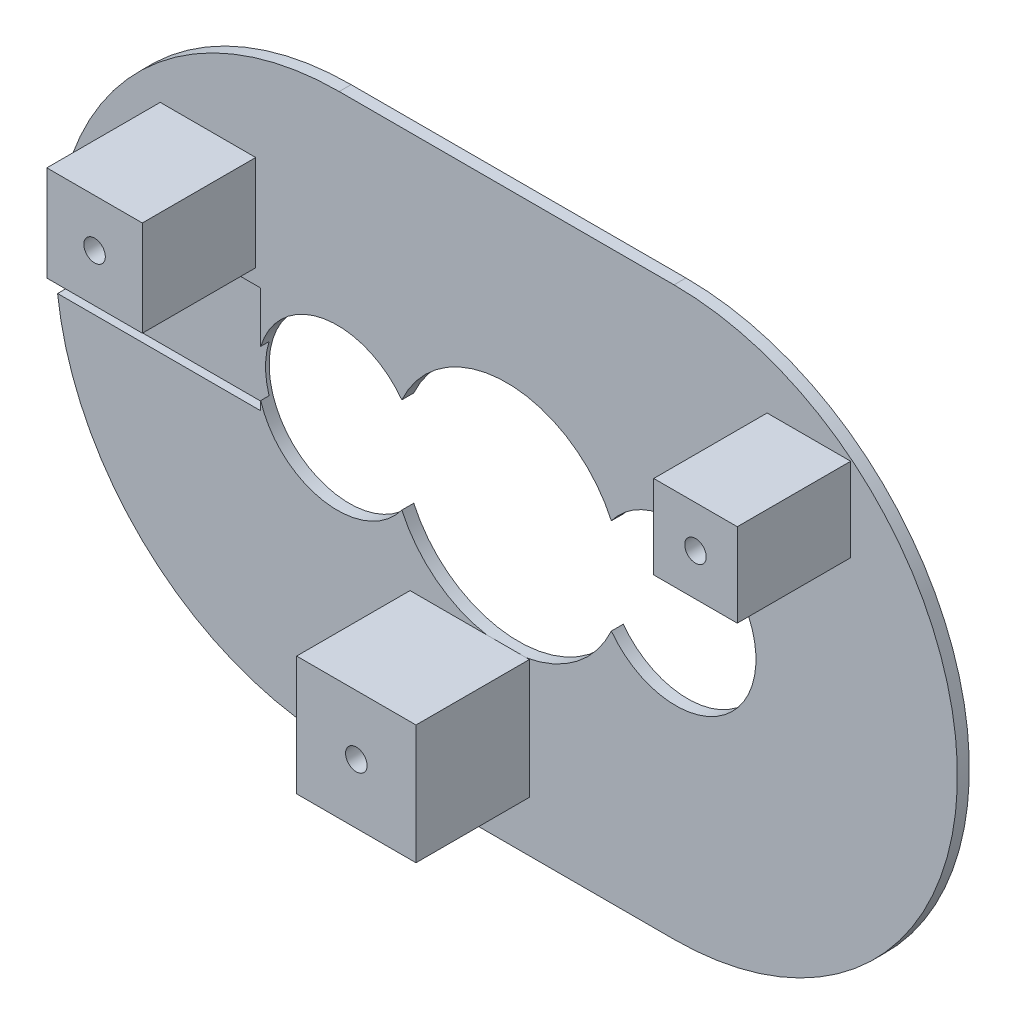
from build123d import *

# Parameters (mm, degrees)
SKETCH1_R               = 9.64479785
BOSS_EXTRUDE1_DEPTH     = 1
SKETCH2_W               = 8
SKETCH2_H               = 8
SKETCH2_W_2             = 10
SKETCH2_H_2             = 10
SKETCH2_W_3             = 7
SKETCH2_H_3             = 7
BOSS_EXTRUDE2_DEPTH     = 9.5
SKETCH3_R               = 0.9
CUT_EXTRUDE1_DEPTH      = 8
CUT_EXTRUDE2_DEPTH      = 0.7
SKETCH6_R               = 6.717749006
CUT_EXTRUDE7_DEPTH      = 10.5
CUT_EXTRUDE7_DEPTH_BACK = 2


with BuildPart() as part:
    # Sketch1 → Boss-Extrude1 (new body)
    with BuildSketch(Plane.XY):
        with BuildLine():
            Line((-14.026724751, 23.745574299), (14.026724751, 23.745574299))
            ThreePointArc((14.026724751, 23.745574299), (37.77229905, 0), (14.026724751, -23.745574299))
            Line((14.026724751, -23.745574299), (-14.026724751, -23.745574299))
            ThreePointArc((-14.026724751, -23.745574299), (-37.77229905, 0), (-14.026724751, 23.745574299))
        make_face()
        Circle(SKETCH1_R, mode=Mode.SUBTRACT)
    extrude(amount=BOSS_EXTRUDE1_DEPTH)

    # Sketch2 → Boss-Extrude2 (add)
    with BuildSketch(Plane.XY.offset(1)):
        with Locations((-25.018703454, 11.462322744)):
            Rectangle(SKETCH2_W, SKETCH2_H)
        with Locations((-3.090198121, -14.497536266)):
            Rectangle(SKETCH2_W_2, SKETCH2_H_2)
        with Locations((25.327090693, 14.846915234)):
            Rectangle(SKETCH2_W_3, SKETCH2_H_3)
    extrude(amount=BOSS_EXTRUDE2_DEPTH)

    # Sketch3 → Cut-Extrude1 (cut)
    with BuildSketch(Plane.XY.offset(10.5)):
        with Locations((-25.018703454, 11.462322744)):
            Circle(SKETCH3_R)
        with Locations((25.327090693, 14.846915234)):
            Circle(SKETCH3_R)
        with Locations((-3.090198121, -14.497536266)):
            Circle(SKETCH3_R)
    extrude(amount=-CUT_EXTRUDE1_DEPTH, mode=Mode.SUBTRACT)

    # Sketch4 → Cut-Extrude2 (cut)
    with BuildSketch(Plane.XY.offset(1)):
        with BuildLine():
            Line((-20.6, 6.2), (-36.948598558, 6.2))
            ThreePointArc((-36.948598558, 6.2), (-37.70555704, 1.779100955), (-37.617693234, -2.705273523))
            Line((-37.617693234, -2.705273523), (-20.6, -2.705273523))
            Line((-20.6, -2.705273523), (-20.6, 6.2))
        make_face()
    extrude(amount=-CUT_EXTRUDE2_DEPTH, mode=Mode.SUBTRACT)

    # Sketch6 → Cut-Extrude7 (cut, two sides)
    with BuildSketch(Plane.XY.offset(1)) as cut_extrude7_sk:
        with Locations((14.176031791, 0)):
            Circle(SKETCH6_R)
        with Locations((-14.176031791, 0)):
            Circle(SKETCH6_R)
    extrude(amount=CUT_EXTRUDE7_DEPTH, mode=Mode.SUBTRACT)
    extrude(cut_extrude7_sk.sketch, amount=-CUT_EXTRUDE7_DEPTH_BACK, mode=Mode.SUBTRACT)


solid = part.part
